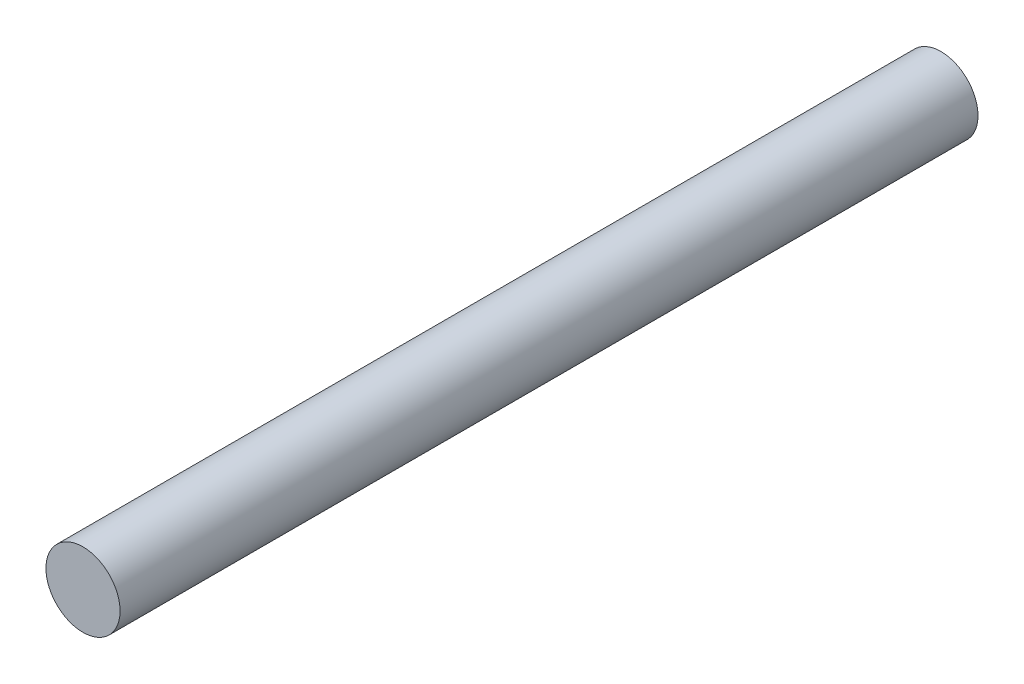
from build123d import *

# Parameters (mm, degrees)
ESBO_O1_R                = 4
RESSALTO_EXTRUS_O1_DEPTH = 46.295


with BuildPart() as part:
    # Esboço1 → Ressalto-extrusão1 (new body, symmetric)
    with BuildSketch(Plane.XY):
        Circle(ESBO_O1_R)
    extrude(amount=RESSALTO_EXTRUS_O1_DEPTH, both=True)


solid = part.part
